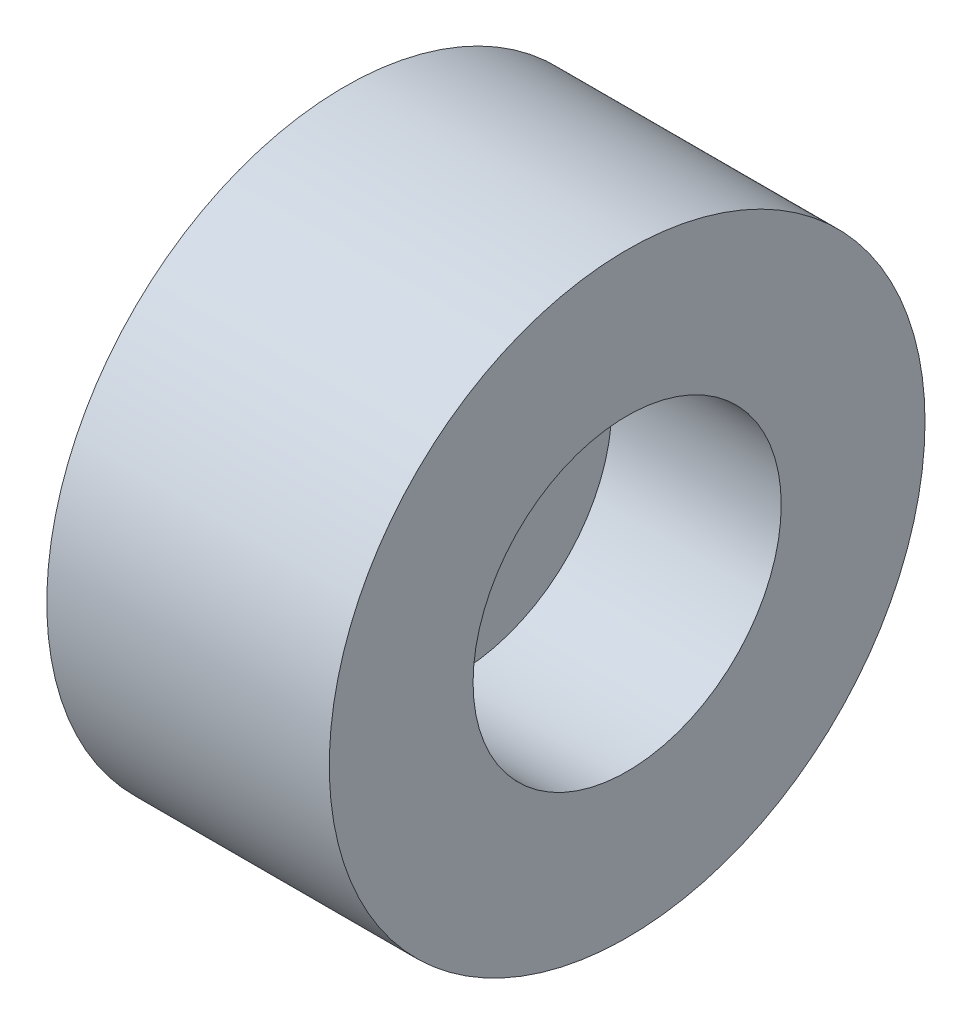
from build123d import *

# Parameters (mm, degrees)
SKETCH1_R           = 5.8
BOSS_EXTRUDE1_DEPTH = 5.5
SKETCH2_R           = 3
CUT_EXTRUDE1_DEPTH  = 3.3
SKETCH3_R           = 1.5
CUT_EXTRUDE2_DEPTH  = 3.3


with BuildPart() as part:
    # Sketch1 → Boss-Extrude1 (new body)
    with BuildSketch(Plane(origin=(0, 0, 0), x_dir=(0, 0, -1), z_dir=(1, 0, 0))):
        Circle(SKETCH1_R)
    extrude(amount=BOSS_EXTRUDE1_DEPTH)

    # Sketch2 → Cut-Extrude1 (cut)
    with BuildSketch(Plane(origin=(5.5, 0, 0), x_dir=(0, 0, -1), z_dir=(1, 0, 0))):
        Circle(SKETCH2_R)
    extrude(amount=-CUT_EXTRUDE1_DEPTH, mode=Mode.SUBTRACT)

    # Sketch3 → Cut-Extrude2 (cut)
    with BuildSketch(Plane(origin=(2.2, 0, 0), x_dir=(0, 0, -1), z_dir=(1, 0, 0))):
        Circle(SKETCH3_R)
    extrude(amount=-CUT_EXTRUDE2_DEPTH, mode=Mode.SUBTRACT)


solid = part.part
